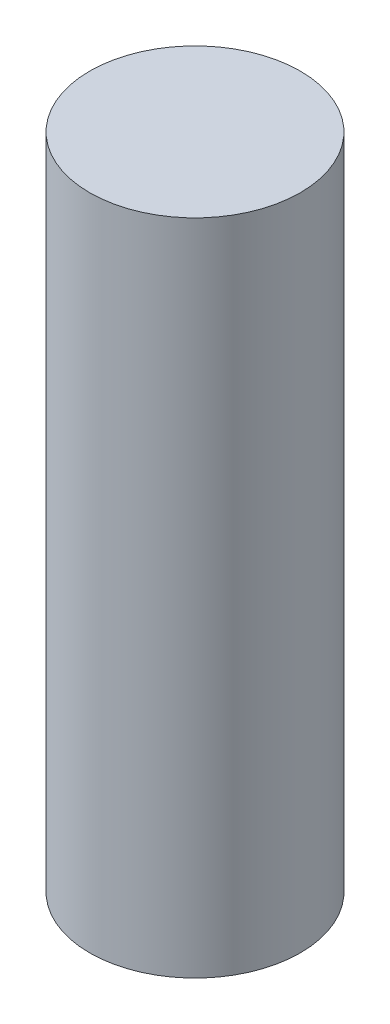
from build123d import *

# Parameters (mm, degrees)
SKETCH1_R           = 4
BOSS_EXTRUDE1_DEPTH = 25


with BuildPart() as part:
    # Sketch1 → Boss-Extrude1 (new body)
    with BuildSketch(Plane(origin=(0, 0, 0), x_dir=(1, 0, 0), z_dir=(0, 1, 0))):
        Circle(SKETCH1_R)
    extrude(amount=BOSS_EXTRUDE1_DEPTH)


solid = part.part
